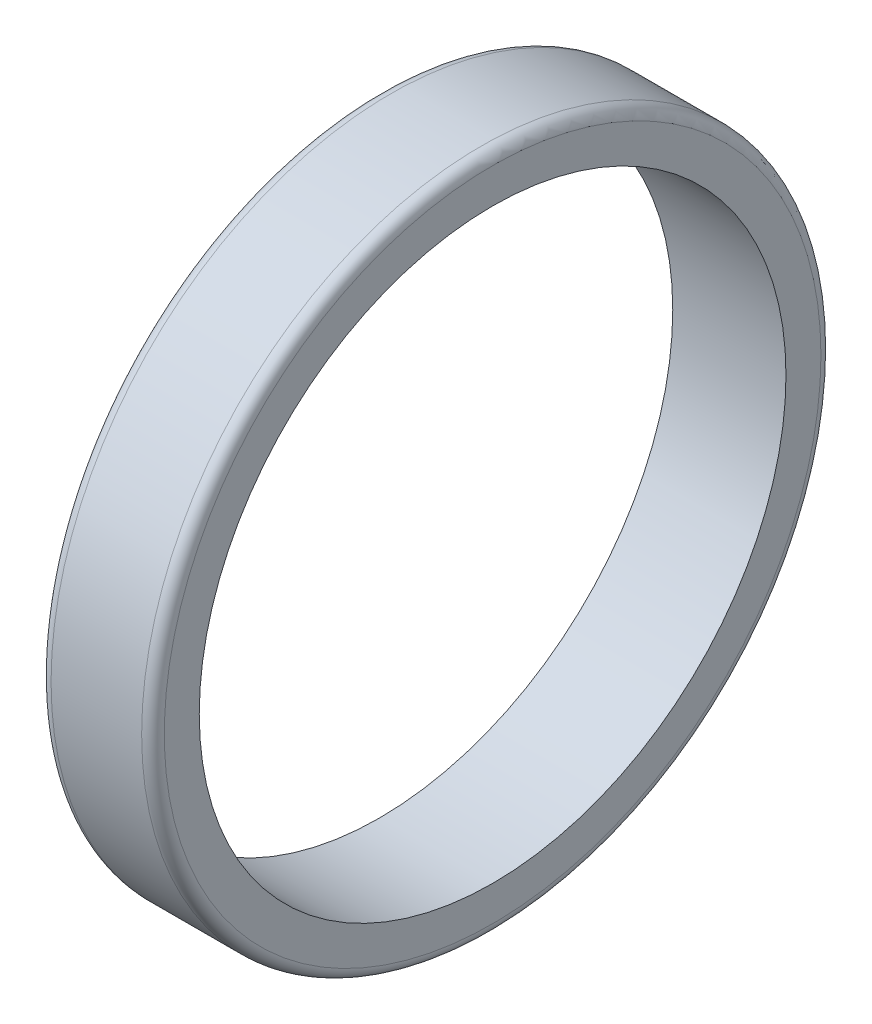
from build123d import *

# Parameters (mm, degrees)
SKETCH1_R           = 76.2
SKETCH1_R_2         = 65.81775
BOSS_EXTRUDE1_DEPTH = 25.4
FILLET1_R           = 2.54


with BuildPart() as part:
    # Sketch1 → Boss-Extrude1 (new body)
    with BuildSketch(Plane(origin=(0, 0, 0), x_dir=(0, 0, -1), z_dir=(1, 0, 0))):
        Circle(SKETCH1_R)
        Circle(SKETCH1_R_2, mode=Mode.SUBTRACT)
    extrude(amount=BOSS_EXTRUDE1_DEPTH)

    # Fillet1
    fillet1_edges = [part.edges().sort_by_distance(p)[0] for p in [
        (0, 0, 76.2),
        (25.4, 0, 76.2),
    ]]
    fillet(fillet1_edges, radius=FILLET1_R)


solid = part.part
